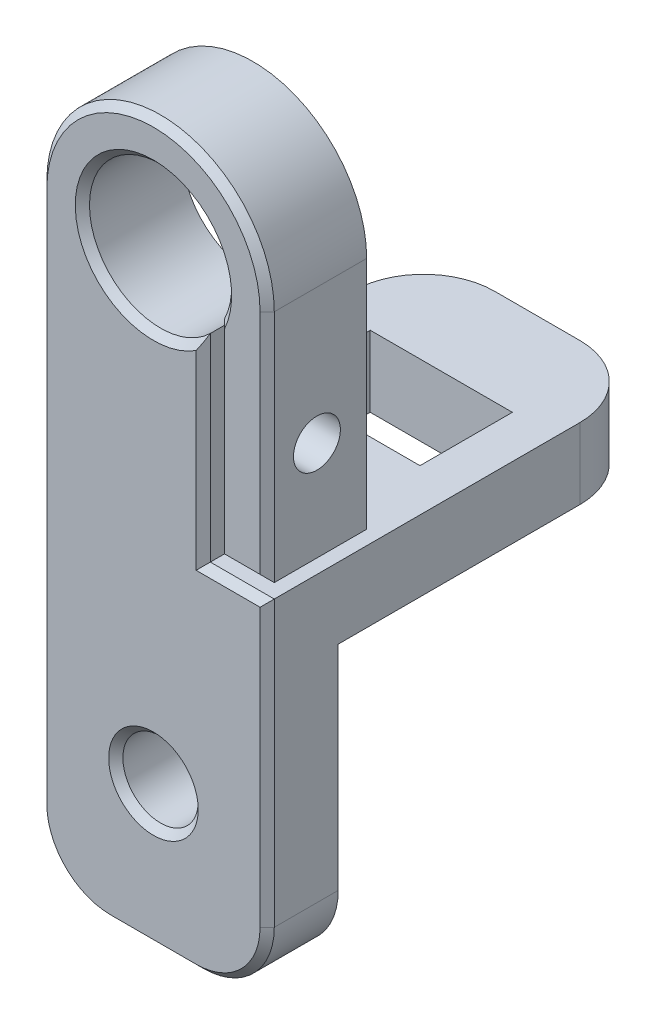
from build123d import *

# Parameters (mm, degrees)
ESBO_O1_R                = 5
ESBO_O1_R_2              = 2.65
RESSALTO_EXTRUS_O3_DEPTH = 7
RESSALTO_EXTRUS_O4_START = -20
ESBO_O3_W                = 10
ESBO_O3_H                = 6.5
RESSALTO_EXTRUS_O4_DEPTH = 5
CORTE_EXTRUS_O2_DEPTH    = 8
ESBO_O6_R                = 1.65
CORTE_EXTRUS_O3_DEPTH    = 17
CORTE_EXTRUS_O4_DEPTH    = 4
CHANFRO1_SIZE            = 2.5
CORTE_EXTRUS_O1_DEPTH    = 2
CHANFRO2_SIZE            = 0.5


with BuildPart() as part:
    # Esboço1 → Ressalto-extrusão3 (new body)
    with BuildSketch(Plane.XY):
        with BuildLine():
            Line((7.982953463, 0.015906926), (7.982953463, -37.484093074))
            ThreePointArc((7.982953463, -37.484093074), (6.518487369, -41.01962698), (2.982953463, -42.484093074))
            Line((2.982953463, -42.484093074), (-3.017046537, -42.484093074))
            ThreePointArc((-3.017046537, -42.484093074), (-6.552580443, -41.01962698), (-8.017046537, -37.484093074))
            Line((-8.017046537, -37.484093074), (-8.017046537, 0.015906926))
            ThreePointArc((-8.017046537, 0.015906926), (-0.017046537, 8.015906926), (7.982953463, 0.015906926))
        make_face()
        with Locations((-0.017046537, 0.015906926)):
            Circle(ESBO_O1_R, mode=Mode.SUBTRACT)
        with Locations((-0.017046537, -32.484093074)):
            Circle(ESBO_O1_R_2, mode=Mode.SUBTRACT)
    extrude(amount=RESSALTO_EXTRUS_O3_DEPTH)

    # Esboço3 → Ressalto-extrusão4 (add)
    with BuildSketch(Plane.XZ.offset(42.484093074).offset(RESSALTO_EXTRUS_O4_START)):
        with BuildLine():
            Line((7.982953463, 0), (-8.017046537, 0))
            Line((-8.017046537, 0), (-8.017046537, -15))
            ThreePointArc((-8.017046537, -15), (-6.552580443, -18.535533906), (-3.017046537, -20))
            Line((-3.017046537, -20), (2.982953463, -20))
            ThreePointArc((2.982953463, -20), (6.518487369, -18.535533906), (7.982953463, -15))
            Line((7.982953463, -15), (7.982953463, 0))
        make_face()
        with Locations((-0.017046537, -10)):
            Rectangle(ESBO_O3_W, ESBO_O3_H, mode=Mode.SUBTRACT)
    extrude(amount=-RESSALTO_EXTRUS_O4_DEPTH)

    # Esboço5 → Corte-extrusão2 (cut, through all)
    with BuildSketch(Plane(origin=(0, 0, 0), x_dir=(-1, 0, 0), z_dir=(0, 0, -1))):
        with BuildLine():
            Line((-4.482953463, -2.163542545), (-4.482953463, -16.484093074))
            Line((-4.482953463, -16.484093074), (-7.982953463, -16.484093074))
            Line((-7.982953463, -16.484093074), (-7.982953463, -17.484093074))
            Line((-7.982953463, -17.484093074), (-3.482953463, -17.484093074))
            Line((-3.482953463, -17.484093074), (-3.482953463, -3.554807288))
            ThreePointArc((-3.482953463, -3.554807288), (-4.04299095, -2.902328089), (-4.482953463, -2.163542545))
        make_face()
    extrude(amount=-CORTE_EXTRUS_O2_DEPTH, mode=Mode.SUBTRACT)

    # Esboço6 → Corte-extrusão3 (cut, through all)
    with BuildSketch(Plane(origin=(7.982953463, 0, 0), x_dir=(0, 0, -1), z_dir=(1, 0, 0))):
        with Locations((-3.5, -9.484093074)):
            Circle(ESBO_O6_R)
    extrude(amount=-CORTE_EXTRUS_O3_DEPTH, mode=Mode.SUBTRACT)

    # Esboço7 → Corte-extrusão4 (cut)
    with BuildSketch(Plane(origin=(-8.017046537, 0, 0), x_dir=(0, 0, -1), z_dir=(1, 0, 0))):
        Polygon((-6.3, -7.86751232), (-6.3, -11.100673827), (-3.5, -12.717254581), (-0.7, -11.100673827), (-0.7, -7.86751232), (-3.5, -6.250931566), align=None)
    extrude(amount=CORTE_EXTRUS_O4_DEPTH, mode=Mode.SUBTRACT)

    # Chanfro1
    chanfro1_edges = [part.edges().sort_by_distance(p)[0] for p in [
        (-2.267046537, -17.484093074, 0),
    ]]
    chamfer(chanfro1_edges, length=CHANFRO1_SIZE)

    # Esboço4 → Corte-extrusão1 (cut)
    with BuildSketch(Plane(origin=(0, 0, 0), x_dir=(-1, 0, 0), z_dir=(0, 0, -1))):
        with BuildLine():
            Line((-2.982953463, -42.484093074), (3.017046537, -42.484093074))
            ThreePointArc((3.017046537, -42.484093074), (6.552580443, -41.01962698), (8.017046537, -37.484093074))
            Line((8.017046537, -37.484093074), (8.017046537, -22.484093074))
            Line((8.017046537, -22.484093074), (-7.982953463, -22.484093074))
            Line((-7.982953463, -22.484093074), (-7.982953463, -37.484093074))
            ThreePointArc((-7.982953463, -37.484093074), (-6.518487369, -41.01962698), (-2.982953463, -42.484093074))
        make_face()
    extrude(amount=-CORTE_EXTRUS_O1_DEPTH, mode=Mode.SUBTRACT)

    # Chanfro2
    chanfro2_edges = [part.edges().sort_by_distance(p)[0] for p in [
        (-2.667046537, -32.484093074, 7),
        (4.482953463, -9.323817809, 7),
        (-4.077084024, 2.934141942, 7),
        (3.482953463, -10.519450181, 7),
        (5.732953463, -17.484093074, 7),
        (7.982953463, -27.484093074, 7),
        (6.518487369, -41.01962698, 7),
        (-0.017046537, -42.484093074, 7),
        (-6.552580443, -41.01962698, 7),
        (-8.017046537, -18.734093074, 7),
        (-0.017046537, 8.015906926, 7),
        (6.232953463, -16.484093074, 7),
    ]]
    chamfer(chanfro2_edges, length=CHANFRO2_SIZE)


solid = part.part
